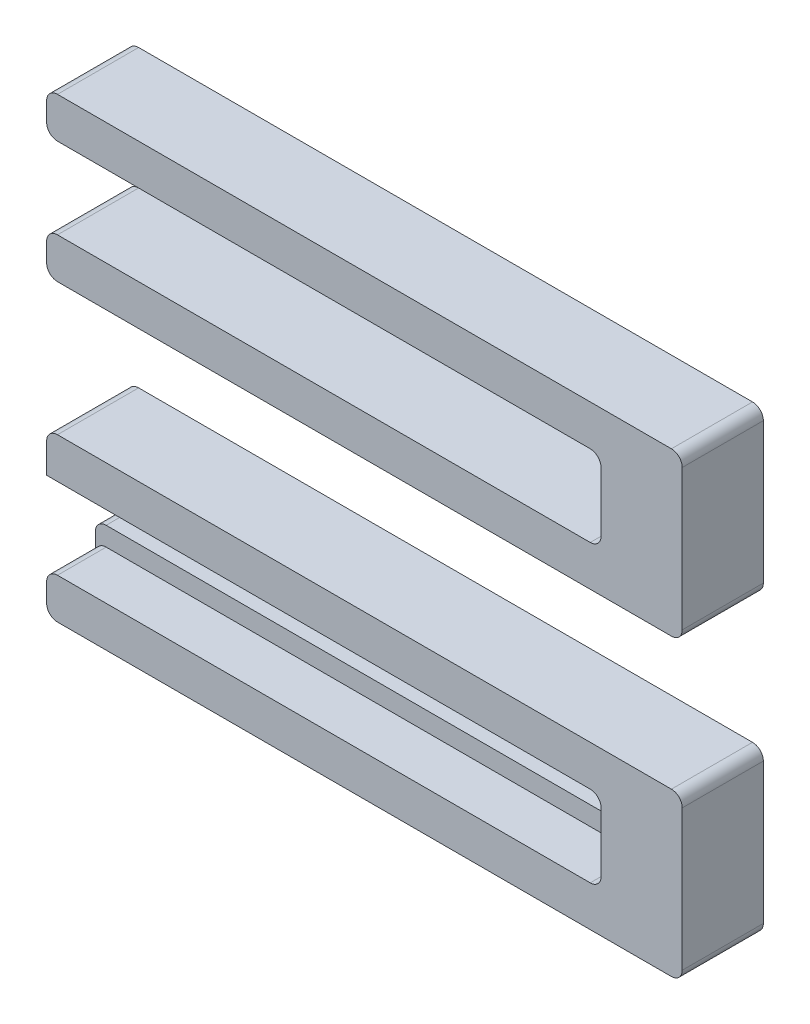
from build123d import *

# Parameters (mm, degrees)
BOSS_EXTRUDE1_DEPTH   = 3
BOSS_EXTRUDE1_2_DEPTH = 3
SKETCH2_4_W           = 20.5
SKETCH2_4_H           = 0.7
BOSS_EXTRUDE3_DEPTH   = 1.2
FILLET2_R             = 0.4
FILLET3_R             = 0.4


with BuildPart() as part:
    # Sketch2 → Boss-Extrude1 (new body)
    with BuildSketch(Plane.XY):
        Polygon((0, 1.5), (0, 0), (23.5, 0), (23.5, 6), (0, 6), (0, 4.5), (20.5, 4.5), (20.5, 1.5), align=None)
    extrude(amount=BOSS_EXTRUDE1_DEPTH)



with BuildPart() as body_2:
    # Sketch2 → Boss-Extrude1 2 (new body)
    with BuildSketch(Plane.XY):
        Polygon((20.5, -6.399471306), (20.5, -9.399471306), (0, -9.399471306), (0, -10.899471306), (23.5, -10.899471306), (23.5, -4.899471306), (0, -4.899471306), (0, -6.399471306), align=None)
    extrude(amount=BOSS_EXTRUDE1_2_DEPTH)


with BuildPart() as part_1:
    add(part.part)

    add(body_2.part)  # Boss-Extrude3 merges body 2
    # Sketch2_4 → Boss-Extrude3 (add)
    with BuildSketch(Plane.XY):
        with Locations((10.25, 4.15)):
            Rectangle(SKETCH2_4_W, SKETCH2_4_H)
        with Locations((10.25, -9.049471306)):
            Rectangle(SKETCH2_4_W, SKETCH2_4_H)
    extrude(amount=BOSS_EXTRUDE3_DEPTH)

    # Fillet2
    fillet2_edges = [part_1.edges().sort_by_distance(p)[0] for p in [
        (0, 4.5, 2.1),
        (20.5, 1.5, 1.5),
        (20.5, 3.8, 0.6),
        (20.5, 4.5, 2.1),
        (23.5, 6, 1.5),
        (23.5, 0, 1.5),
        (0, 0, 1.5),
        (0, 1.5, 1.5),
        (0, 3.8, 0.6),
        (0, 6, 1.5),
    ]]
    fillet(fillet2_edges, radius=FILLET2_R)

    # Fillet3
    fillet3_edges = [part_1.edges().sort_by_distance(p)[0] for p in [
        (23.5, -10.899471306, 1.5),
        (23.5, -4.899471306, 1.5),
        (20.5, -6.399471306, 1.5),
        (20.5, -9.399471306, 2.1),
        (20.5, -8.699471306, 0.6),
        (0, -10.899471306, 1.5),
        (0, -9.399471306, 2.1),
        (0, -8.699471306, 0.6),
        (0, -4.899471306, 1.5),
    ]]
    fillet(fillet3_edges, radius=FILLET3_R)


solid = part_1.part
